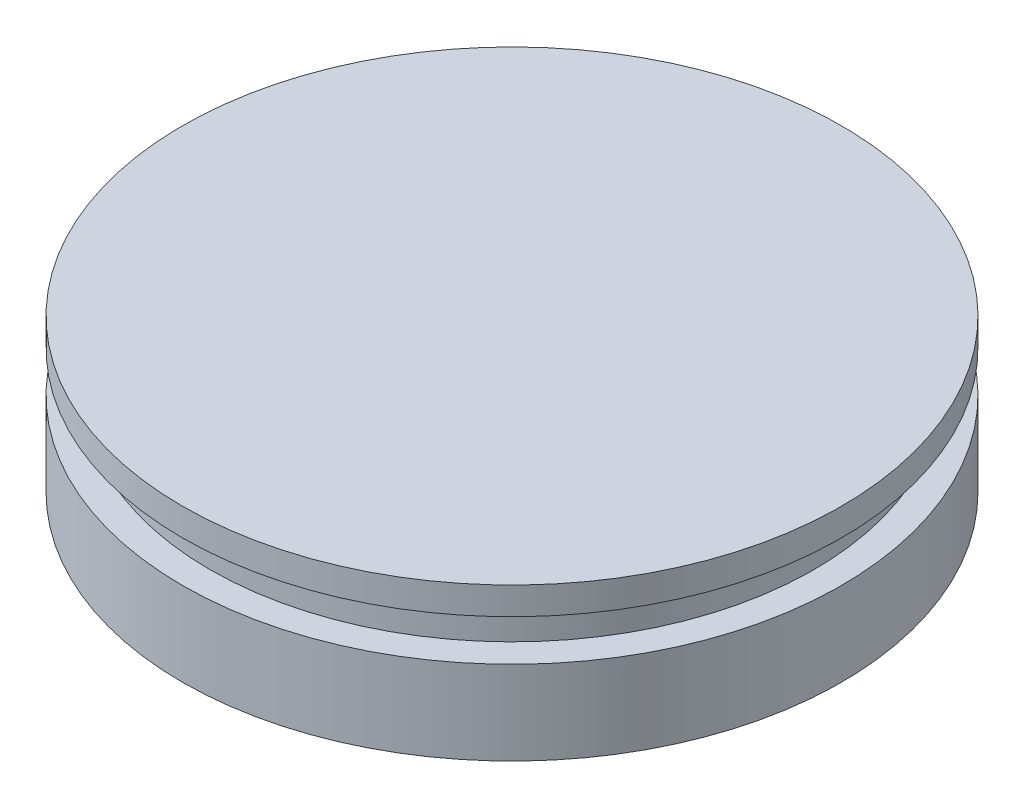
from build123d import *


with BuildPart() as part:
    # Sketch1 → Revolve1 (revolve)
    with BuildSketch(Plane.XY):
        with BuildLine():
            Line((-69.85, 1876.044), (-69.85, 1866.519))
            Line((-69.85, 1866.519), (-76.2, 1866.519))
            Line((-76.2, 1866.519), (-76.2, 1847.131150075))
            ThreePointArc((-76.2, 1847.131150075), (-39.735129913, 1863.934789641), (0, 1869.694))
            Line((0, 1869.694), (0, 1882.394))
            Line((0, 1882.394), (-76.2, 1882.394))
            Line((-76.2, 1882.394), (-76.2, 1876.044))
            Line((-76.2, 1876.044), (-69.85, 1876.044))
        make_face()
    revolve(axis=Axis((0, 50.358015581, 0), (0, -1, 0)))


solid = part.part
